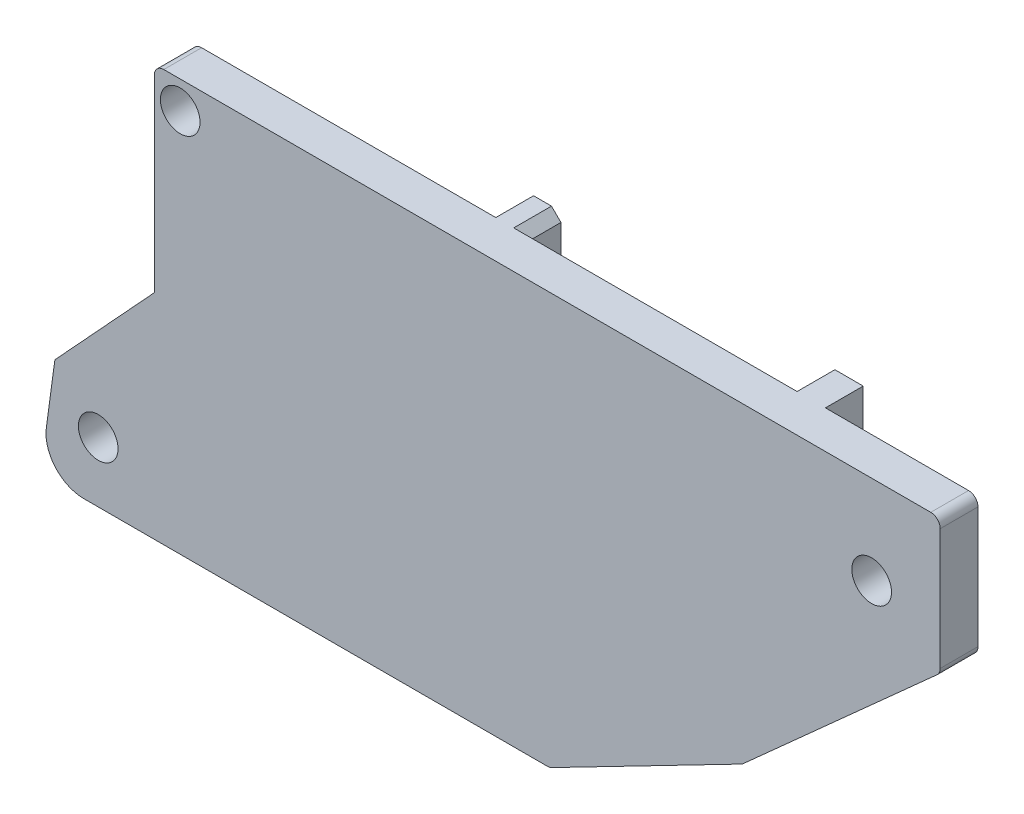
from build123d import *

# Parameters (mm, degrees)
ESQUISSE1_R        = 1.05
BOSS_EXTRU_1_DEPTH = 2
CONG_1_R           = 2
CONG_2_R           = 0.5
BOSS_EXTRU_2_DEPTH = 2
CHANFREIN1_SIZE    = 0.5


with BuildPart() as part:
    # Esquisse1 → Boss.-Extru.1 (new body)
    with BuildSketch(Plane.XY):
        Polygon((-20.8, 10.895), (20.8, 10.895), (20.8, 3.765359203), (10.324093605, -5.633066028), (0.127924824, -10.895), (-20.8, -10.895), (-26.825567122, -10.895), (-26.065636187, -5.293625083), (-20.8, 0.415783742), align=None)
        with Locations((17.17, 6.195)):
            Circle(ESQUISSE1_R, mode=Mode.SUBTRACT)
        with Locations((-19.43, 9.435)):
            Circle(ESQUISSE1_R, mode=Mode.SUBTRACT)
        with Locations((-23.770918846, -7.705)):
            Circle(ESQUISSE1_R, mode=Mode.SUBTRACT)
    extrude(amount=BOSS_EXTRU_1_DEPTH)

    # Congé1
    cong_1_edges = [part.edges().sort_by_distance(p)[0] for p in [
        (-26.825567122, -10.895, 1),
    ]]
    fillet(cong_1_edges, radius=CONG_1_R)

    # Congé2
    cong_2_edges = [part.edges().sort_by_distance(p)[0] for p in [
        (-20.8, 10.895, 1),
        (20.8, 10.895, 1),
        (20.8, 3.765359203, 1),
        (10.324093605, -5.633066028, 1),
        (0.127924824, -10.895, 1),
    ]]
    fillet(cong_2_edges, radius=CONG_2_R)

    # Esquisse2 → Boss.-Extru.2 (add)
    with BuildSketch(Plane(origin=(0, 0, 0), x_dir=(-1, 0, 0), z_dir=(0, 0, -1))):
        Polygon((-10.723313352, 9.373462564), (-10.723313352, -4.635), (3.276686648, -4.635), (3.276686648, 9.365), (3.276686648, 10.895), (5.226686648, 10.895), (5.226686648, 6.495), (5.226686648, -7.505), (19.226686648, -7.505), (19.226686648, 6.495), (20.8, 6.495), (20.8, -9.505), (4.398259523, -9.505), (1.528259523, -6.635), (-8.382623427, -6.635), (-10.371769863, -5.590293429), (-12.723313352, -3.480613862), (-12.723313352, 10.895), (-10.723313352, 10.895), align=None)
    extrude(amount=BOSS_EXTRU_2_DEPTH)

    # Chanfrein1
    chanfrein1_edges = [part.edges().sort_by_distance(p)[0] for p in [
        (10.723313352, 10.895, -1),
        (-19.226686648, 6.495, -1),
        (-19.226686648, -7.505, -1),
        (-5.226686648, -7.505, -1),
        (-5.226686648, 10.895, -1),
        (-3.276686648, 10.895, -1),
        (-3.276686648, -4.635, -1),
        (10.723313352, -4.635, -1),
    ]]
    chamfer(chanfrein1_edges, length=CHANFREIN1_SIZE)


solid = part.part
